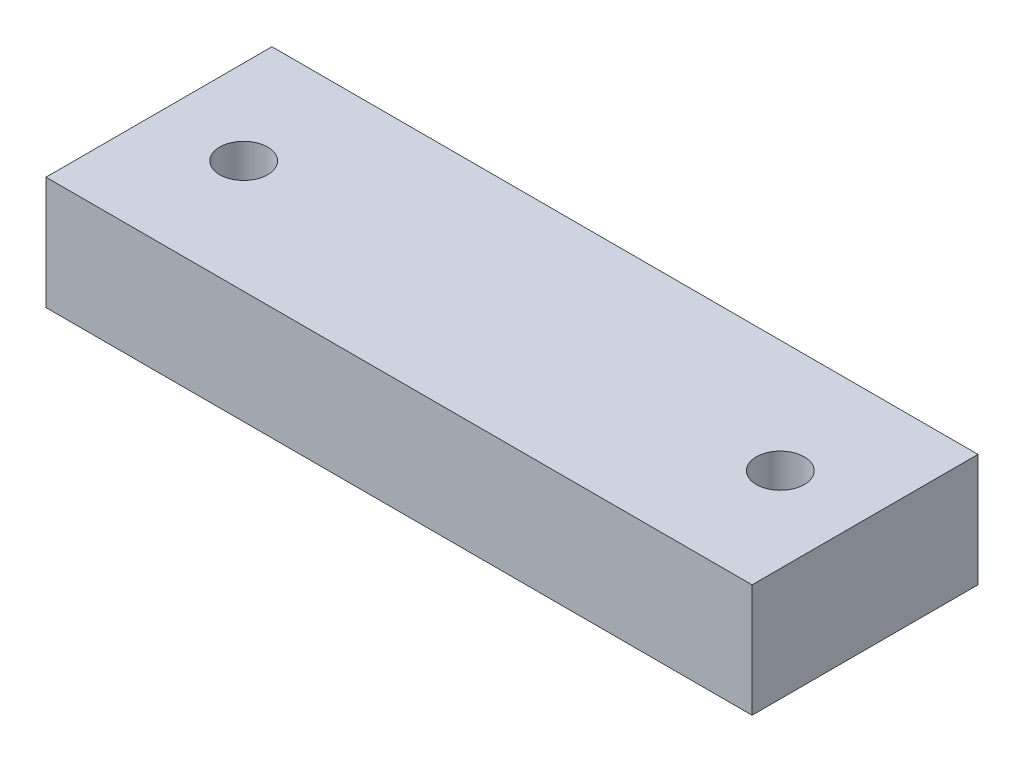
from build123d import *

# Parameters (mm, degrees)
SKETCH_1_W              = 125
SKETCH_1_H              = 40
EXTRUDE_1_DEPTH         = 20
HOLE_WIZARD_M10_1_D     = 8.5
HOLE_WIZARD_M10_1_DEPTH = 24.5
HOLE_WIZARD_M10_1_TIP   = 2.553657631


with BuildPart() as part:
    # 草图1 → 凸台-拉伸1 (new body)
    with BuildSketch(Plane(origin=(0, 0, 0), x_dir=(1, 0, 0), z_dir=(0, 1, 0))):
        Rectangle(SKETCH_1_W, SKETCH_1_H)
    extrude(amount=EXTRUDE_1_DEPTH)

    # M10 螺纹孔1
    with Locations(Plane(origin=(0, 20, 0), x_dir=(1, 0, 0), z_dir=(0, 1, 0))):
        with Locations((47.5, 0), (-47.5, 0)):
            Hole(HOLE_WIZARD_M10_1_D / 2, depth=HOLE_WIZARD_M10_1_DEPTH)
            with Locations((0, 0, -(HOLE_WIZARD_M10_1_DEPTH + HOLE_WIZARD_M10_1_TIP / 2))):  # 118° drill point
                Cone(0, HOLE_WIZARD_M10_1_D / 2, HOLE_WIZARD_M10_1_TIP, mode=Mode.SUBTRACT)


solid = part.part
